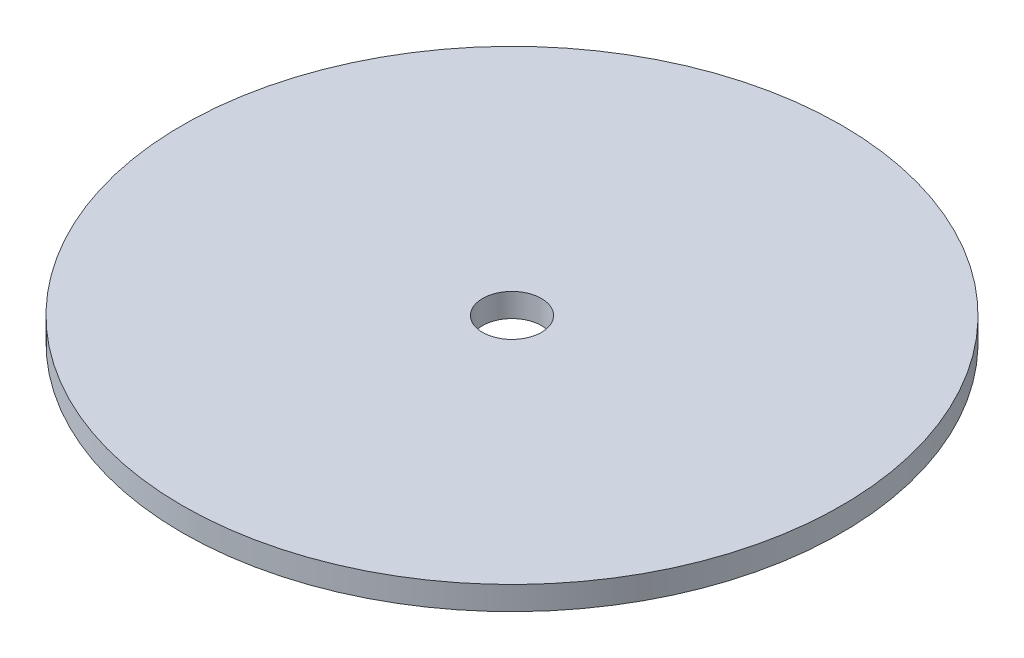
from build123d import *

# Parameters (mm, degrees)
SKETCH1_W = 25.5
SKETCH1_H = 2


with BuildPart() as part:
    # Sketch1 → Revolve1 (revolve)
    with BuildSketch(Plane.XY):
        with Locations((15.25, 1)):
            Rectangle(SKETCH1_W, SKETCH1_H)
    revolve(axis=Axis((0, 0, 0), (0, 1, 0)))


solid = part.part
